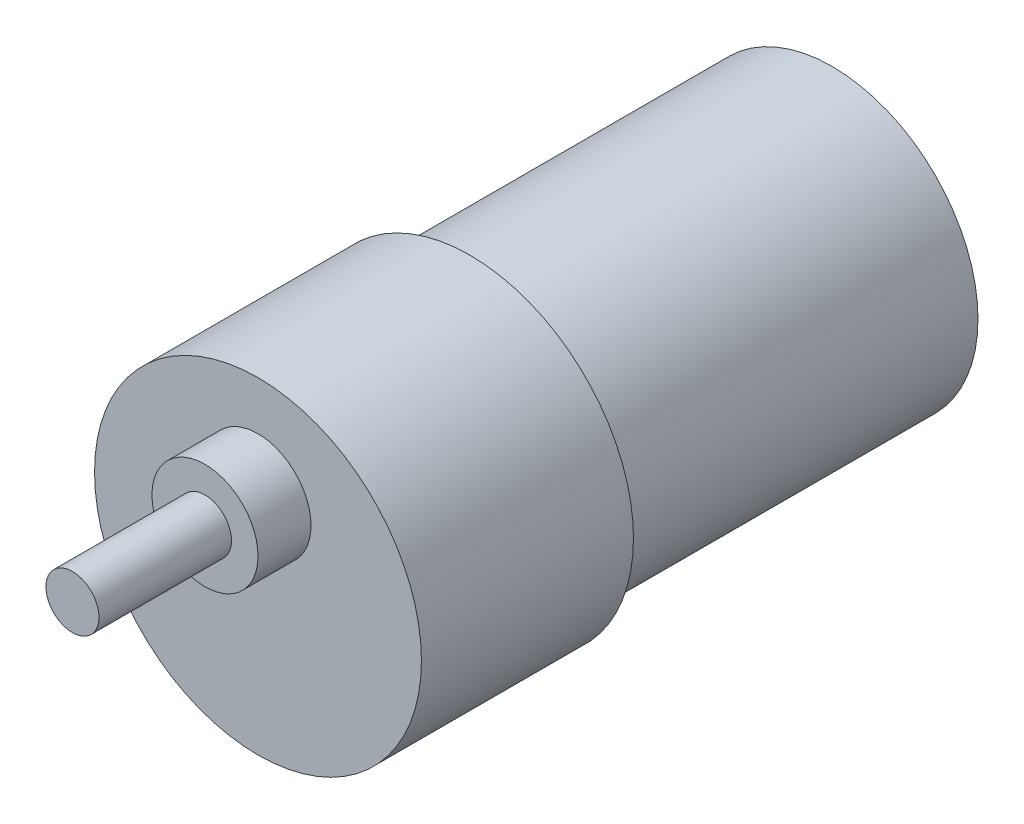
from build123d import *

# Parameters (mm, degrees)
SKETCH1_R           = 16.5
BOSS_EXTRUDE1_DEPTH = 20.5
SKETCH2_R           = 18.5
BOSS_EXTRUDE2_DEPTH = 24
SKETCH3_R           = 6
BOSS_EXTRUDE3_DEPTH = 6
SKETCH4_R           = 3
BOSS_EXTRUDE4_DEPTH = 15


with BuildPart() as part:
    # Sketch1 → Boss-Extrude1 (new body, symmetric)
    with BuildSketch(Plane.XY):
        Circle(SKETCH1_R)
    extrude(amount=BOSS_EXTRUDE1_DEPTH, both=True)

    # Sketch2 → Boss-Extrude2 (add)
    with BuildSketch(Plane.XY.offset(20.5)):
        Circle(SKETCH2_R)
    extrude(amount=BOSS_EXTRUDE2_DEPTH)

    # Sketch3 → Boss-Extrude3 (add)
    with BuildSketch(Plane.XY.offset(44.5)):
        with Locations((0, 7)):
            Circle(SKETCH3_R)
    extrude(amount=BOSS_EXTRUDE3_DEPTH)

    # Sketch4 → Boss-Extrude4 (add)
    with BuildSketch(Plane.XY.offset(50.5)):
        with Locations((0, 7)):
            Circle(SKETCH4_R)
    extrude(amount=BOSS_EXTRUDE4_DEPTH)


solid = part.part
